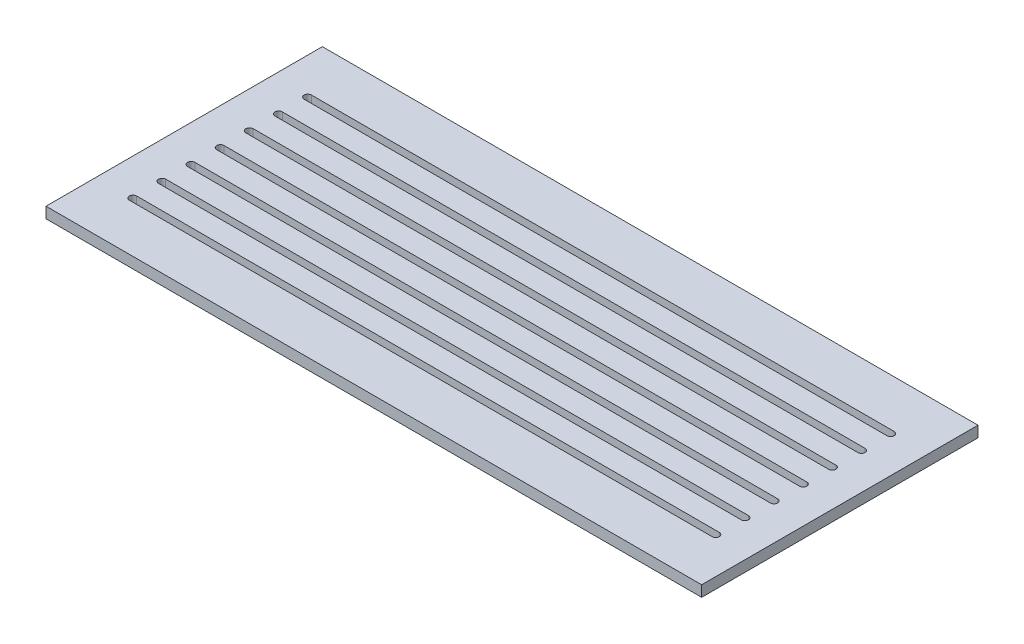
from build123d import *

# Parameters (mm, degrees)
SKETCH1_W           = 180
SKETCH1_H           = 75.87
BOSS_EXTRUDE1_DEPTH = 3


with BuildPart() as part:
    # Sketch1 → Boss-Extrude1 (new body)
    with BuildSketch(Plane(origin=(0, 0, 0), x_dir=(1, 0, 0), z_dir=(0, 1, 0))):
        with Locations((-5.566969943, 8.461475771)):
            Rectangle(SKETCH1_W, SKETCH1_H)
        with BuildLine():
            Line((-85.566969943, 25.396475771), (74.433030057, 25.396475771))
            ThreePointArc((74.433030057, 25.396475771), (75.433030057, 24.396475771), (74.433030057, 23.396475771))
            Line((74.433030057, 23.396475771), (-85.566969943, 23.396475771))
            ThreePointArc((-85.566969943, 23.396475771), (-86.566969943, 24.396475771), (-85.566969943, 25.396475771))
        make_face(mode=Mode.SUBTRACT)
        with BuildLine():
            Line((-85.566969943, 33.396475771), (74.433030057, 33.396475771))
            ThreePointArc((74.433030057, 33.396475771), (75.433030057, 32.396475771), (74.433030057, 31.396475771))
            Line((74.433030057, 31.396475771), (-85.566969943, 31.396475771))
            ThreePointArc((-85.566969943, 31.396475771), (-86.566969943, 32.396475771), (-85.566969943, 33.396475771))
        make_face(mode=Mode.SUBTRACT)
        with BuildLine():
            Line((-85.566969943, 17.396475771), (74.433030057, 17.396475771))
            ThreePointArc((74.433030057, 17.396475771), (75.433030057, 16.396475771), (74.433030057, 15.396475771))
            Line((74.433030057, 15.396475771), (-85.566969943, 15.396475771))
            ThreePointArc((-85.566969943, 15.396475771), (-86.566969943, 16.396475771), (-85.566969943, 17.396475771))
        make_face(mode=Mode.SUBTRACT)
        with BuildLine():
            Line((-85.566969943, 9.396475771), (74.433030057, 9.396475771))
            ThreePointArc((74.433030057, 9.396475771), (75.433030057, 8.396475771), (74.433030057, 7.396475771))
            Line((74.433030057, 7.396475771), (-85.566969943, 7.396475771))
            ThreePointArc((-85.566969943, 7.396475771), (-86.566969943, 8.396475771), (-85.566969943, 9.396475771))
        make_face(mode=Mode.SUBTRACT)
        with BuildLine():
            Line((-85.566969943, 1.396475771), (74.433030057, 1.396475771))
            ThreePointArc((74.433030057, 1.396475771), (75.433030057, 0.396475771), (74.433030057, -0.603524229))
            Line((74.433030057, -0.603524229), (-85.566969943, -0.603524229))
            ThreePointArc((-85.566969943, -0.603524229), (-86.566969943, 0.396475771), (-85.566969943, 1.396475771))
        make_face(mode=Mode.SUBTRACT)
        with BuildLine():
            Line((-85.566969943, -6.603524229), (74.433030057, -6.603524229))
            ThreePointArc((74.433030057, -6.603524229), (75.433030057, -7.603524229), (74.433030057, -8.603524229))
            Line((74.433030057, -8.603524229), (-85.566969943, -8.603524229))
            ThreePointArc((-85.566969943, -8.603524229), (-86.566969943, -7.603524229), (-85.566969943, -6.603524229))
        make_face(mode=Mode.SUBTRACT)
        with BuildLine():
            Line((-85.566969943, -14.603524229), (74.433030057, -14.603524229))
            ThreePointArc((74.433030057, -14.603524229), (75.433030057, -15.603524229), (74.433030057, -16.603524229))
            Line((74.433030057, -16.603524229), (-85.566969943, -16.603524229))
            ThreePointArc((-85.566969943, -16.603524229), (-86.566969943, -15.603524229), (-85.566969943, -14.603524229))
        make_face(mode=Mode.SUBTRACT)
    extrude(amount=BOSS_EXTRUDE1_DEPTH)


solid = part.part
